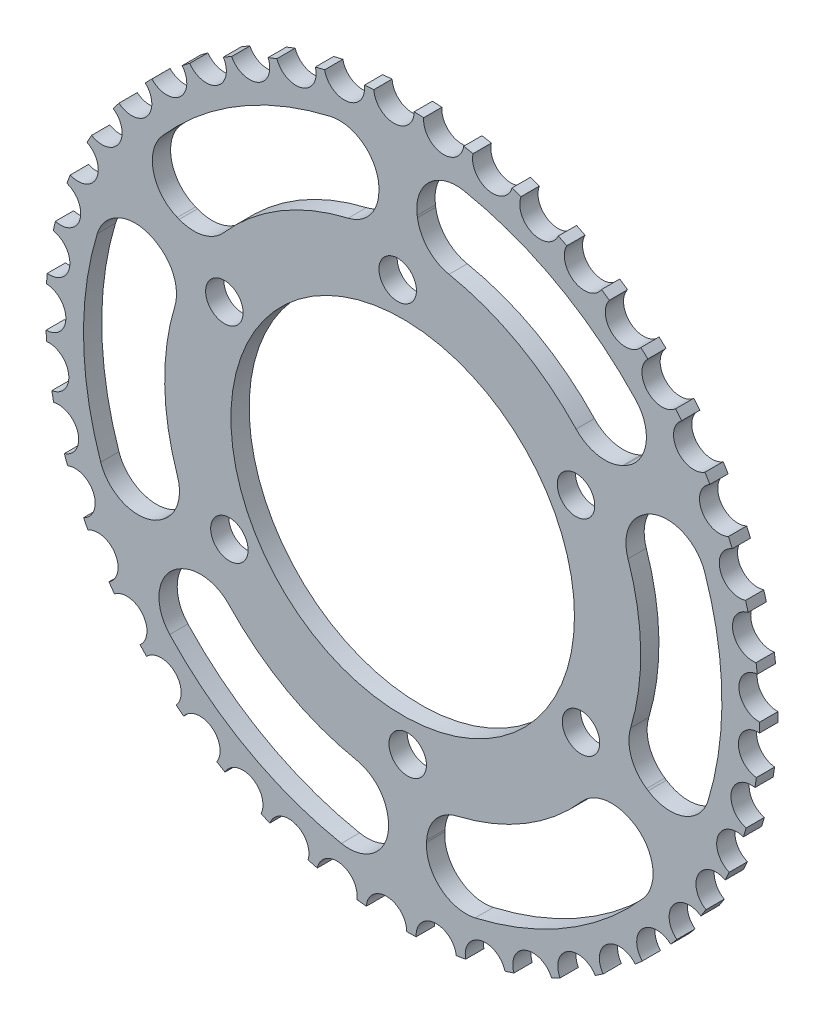
from build123d import *

# Parameters (mm, degrees)
SKETCH1_R           = 114.3
BOSS_EXTRUDE1_DEPTH = 5.842
SKETCH2_R           = 54.99989
CUT_EXTRUDE2_DEPTH  = 6.842
SKETCH3_R           = 6
CUT_EXTRUDE3_DEPTH  = 6.842
SKETCH5_R           = 6.455664
CUT_EXTRUDE6_DEPTH  = 5.842
CUT_EXTRUDE7_DEPTH  = 5.842
FILLET2_R           = 12.7


with BuildPart() as part:
    # Sketch1 → Boss-Extrude1 (new body)
    with BuildSketch(Plane.XY):
        Circle(SKETCH1_R)
    extrude(amount=BOSS_EXTRUDE1_DEPTH)

    # Sketch2 → Cut-Extrude2 (cut, through all)
    with BuildSketch(Plane.XY):
        Circle(SKETCH2_R)
    extrude(amount=CUT_EXTRUDE2_DEPTH, mode=Mode.SUBTRACT)

    # Sketch3 → Cut-Extrude3 (cut, through all)
    with BuildSketch(Plane.XY):
        with Locations((-1.605669379, 65.000124)):
            Circle(SKETCH3_R)
        with Locations((55.488923944, 33.890612472)):
            Circle(SKETCH3_R)
        with Locations((57.094593323, -31.109511528)):
            Circle(SKETCH3_R)
        with Locations((1.605669379, -65.000124)):
            Circle(SKETCH3_R)
        with Locations((-55.488923944, -33.890612472)):
            Circle(SKETCH3_R)
        with Locations((-57.094593323, 31.109511528)):
            Circle(SKETCH3_R)
    extrude(amount=CUT_EXTRUDE3_DEPTH, mode=Mode.SUBTRACT)

    # Sketch5 → Cut-Extrude6 (cut)
    with BuildSketch(Plane.XY.offset(5.842)):
        with Locations((-2.781848486, 114.266142488)):
            Circle(SKETCH5_R)
        with Locations((13.147997657, 113.541270724)):
            Circle(SKETCH5_R)
        with Locations((28.821932982, 110.606447277)):
            Circle(SKETCH5_R)
        with Locations((43.934882165, 105.518795147)):
            Circle(SKETCH5_R)
        with Locations((58.192688842, 98.377339695)):
            Circle(SKETCH5_R)
        with Locations((71.317841024, 89.321081228)):
            Circle(SKETCH5_R)
        with Locations((83.054872553, 78.526289516)):
            Circle(SKETCH5_R)
        with Locations((93.175335461, 66.203072902)):
            Circle(SKETCH5_R)
        with Locations((101.482246451, 52.591288778)):
            Circle(SKETCH5_R)
        with Locations((107.813920947, 37.95587504)):
            Circle(SKETCH5_R)
        with Locations((112.047120109, 22.581693368)):
            Circle(SKETCH5_R)
        with Locations((114.099449529, 6.767984722)):
            Circle(SKETCH5_R)
        with Locations((113.93096295, -9.177455049)):
            Circle(SKETCH5_R)
        with Locations((111.544939773, -24.944266097)):
            Circle(SKETCH5_R)
        with Locations((106.987821223, -40.225565378)):
            Circle(SKETCH5_R)
        with Locations((100.34830643, -54.723919786)):
            Circle(SKETCH5_R)
        with Locations((91.755625996, -68.157135342)):
            Circle(SKETCH5_R)
        with Locations((81.377026673, -80.263749787)):
            Circle(SKETCH5_R)
        with Locations((69.414516091, -90.80812164)):
            Circle(SKETCH5_R)
        with Locations((56.100930911, -99.585016699)):
            Circle(SKETCH5_R)
        with Locations((41.695404925, -106.423602684)):
            Circle(SKETCH5_R)
        with Locations((26.47832531, -111.190774297)):
            Circle(SKETCH5_R)
        with Locations((10.745875211, -113.793743967)):
            Circle(SKETCH5_R)
        with Locations((-5.195731126, -114.181847848)):
            Circle(SKETCH5_R)
        with Locations((-21.036208466, -112.347531942)):
            Circle(SKETCH5_R)
        with Locations((-36.467239937, -108.326499119)):
            Circle(SKETCH5_R)
        with Locations((-51.188478063, -102.197014211)):
            Circle(SKETCH5_R)
        with Locations((-64.91339069, -94.078380668)):
            Circle(SKETCH5_R)
        with Locations((-77.374838005, -84.128618458)):
            Circle(SKETCH5_R)
        with Locations((-88.330272111, -72.541388385)):
            Circle(SKETCH5_R)
        with Locations((-97.566457944, -59.542222702)):
            Circle(SKETCH5_R)
        with Locations((-104.903623654, -45.384135382)):
            Circle(SKETCH5_R)
        with Locations((-110.198959655, -30.34269749)):
            Circle(SKETCH5_R)
        with Locations((-113.349398256, -14.710673506)):
            Circle(SKETCH5_R)
        with Locations((-114.293619753, 1.207677004)):
            Circle(SKETCH5_R)
        with Locations((-113.013245949, 17.102521456)):
            Circle(SKETCH5_R)
        with Locations((-109.533197863, 32.664484781)):
            Circle(SKETCH5_R)
        with Locations((-103.921210672, 47.590671065)):
            Circle(SKETCH5_R)
        with Locations((-96.286515325, 61.59055907)):
            Circle(SKETCH5_R)
        with Locations((-86.777712481, 74.391656902)):
            Circle(SKETCH5_R)
        with Locations((-75.579880172, 85.744805751)):
            Circle(SKETCH5_R)
        with Locations((-62.910971466, 95.429029489)):
            Circle(SKETCH5_R)
        with Locations((-49.017572261, 103.255835717)):
            Circle(SKETCH5_R)
        with Locations((-34.170101768, 109.072884555)):
            Circle(SKETCH5_R)
        with Locations((-18.657549112, 112.766953764)):
            Circle(SKETCH5_R)
    extrude(amount=-CUT_EXTRUDE6_DEPTH, mode=Mode.SUBTRACT)

    # Sketch7 → Cut-Extrude7 (cut)
    with BuildSketch(Plane.XY.offset(5.842)):
        with BuildLine():
            Line((6.104681434, 75.955071355), (2.286087866, 102.175119687))
            ThreePointArc((2.286087866, 102.175119687), (49.207004526, 89.574840142), (85.008204299, 56.732587485))
            Line((85.008204299, 56.732587485), (61.439953951, 45.072963721))
            ThreePointArc((61.439953951, 45.072963721), (37.134829814, 66.539044288), (6.104681434, 75.955071355))
        make_face()
        with BuildLine():
            Line((68.831362057, 32.690726474), (89.629293217, 49.107749676))
            ThreePointArc((89.629293217, 49.107749676), (102.177589366, 2.172904108), (91.635964134, -45.25297071))
            Line((91.635964134, -45.25297071), (69.754308581, -30.672079068))
            ThreePointArc((69.754308581, -30.672079068), (76.191917603, 1.10981616), (68.831362057, 32.690726474))
        make_face()
        with BuildLine():
            Line((62.726680623, -43.264344882), (87.343205351, -53.067370011))
            ThreePointArc((87.343205351, -53.067370011), (52.97058484, -87.401936034), (6.627759835, -101.985558195))
            Line((6.627759835, -101.985558195), (8.314354631, -75.745042789))
            ThreePointArc((8.314354631, -75.745042789), (39.05708779, -65.429228128), (62.726680623, -43.264344882))
        make_face()
        with BuildLine():
            Line((-6.104681434, -75.955071355), (-2.286087866, -102.175119687))
            ThreePointArc((-2.286087866, -102.175119687), (-49.207004526, -89.574840142), (-85.008204299, -56.732587485))
            Line((-85.008204299, -56.732587485), (-61.439953951, -45.072963721))
            ThreePointArc((-61.439953951, -45.072963721), (-37.134829814, -66.539044288), (-6.104681434, -75.955071355))
        make_face()
        with BuildLine():
            Line((-68.831362057, -32.690726474), (-89.629293217, -49.107749676))
            ThreePointArc((-89.629293217, -49.107749676), (-102.177589366, -2.172904108), (-91.635964134, 45.25297071))
            Line((-91.635964134, 45.25297071), (-69.754308581, 30.672079068))
            ThreePointArc((-69.754308581, 30.672079068), (-76.191917603, -1.10981616), (-68.831362057, -32.690726474))
        make_face()
        with BuildLine():
            Line((-62.726680623, 43.264344882), (-87.343205351, 53.067370011))
            ThreePointArc((-87.343205351, 53.067370011), (-52.97058484, 87.401936034), (-6.627759835, 101.985558195))
            Line((-6.627759835, 101.985558195), (-8.314354631, 75.745042789))
            ThreePointArc((-8.314354631, 75.745042789), (-39.05708779, 65.429228128), (-62.726680623, 43.264344882))
        make_face()
    extrude(amount=-CUT_EXTRUDE7_DEPTH, mode=Mode.SUBTRACT)

    # Fillet2
    fillet2_edges = [part.edges().sort_by_distance(p)[0] for p in [
        (87.343205351, -53.067370011, 2.921),
        (6.627759835, -101.985558195, 2.921),
        (8.314354631, -75.745042789, 2.921),
        (62.726680623, -43.264344882, 2.921),
        (89.629293217, 49.107749676, 2.921),
        (91.635964134, -45.25297071, 2.921),
        (69.754308581, -30.672079068, 2.921),
        (68.831362057, 32.690726474, 2.921),
        (-89.629293217, -49.107749676, 2.921),
        (-91.635964134, 45.25297071, 2.921),
        (-69.754308581, 30.672079068, 2.921),
        (-68.831362057, -32.690726474, 2.921),
        (-2.286087866, -102.175119687, 2.921),
        (-85.008204299, -56.732587485, 2.921),
        (-61.439953951, -45.072963721, 2.921),
        (-6.104681434, -75.955071355, 2.921),
        (-87.343205351, 53.067370011, 2.921),
        (-6.627759835, 101.985558195, 2.921),
        (-8.314354631, 75.745042789, 2.921),
        (-62.726680623, 43.264344882, 2.921),
        (2.286087866, 102.175119687, 2.921),
        (85.008204299, 56.732587485, 2.921),
        (61.439953951, 45.072963721, 2.921),
        (6.104681434, 75.955071355, 2.921),
    ]]
    fillet(fillet2_edges, radius=FILLET2_R)


solid = part.part
